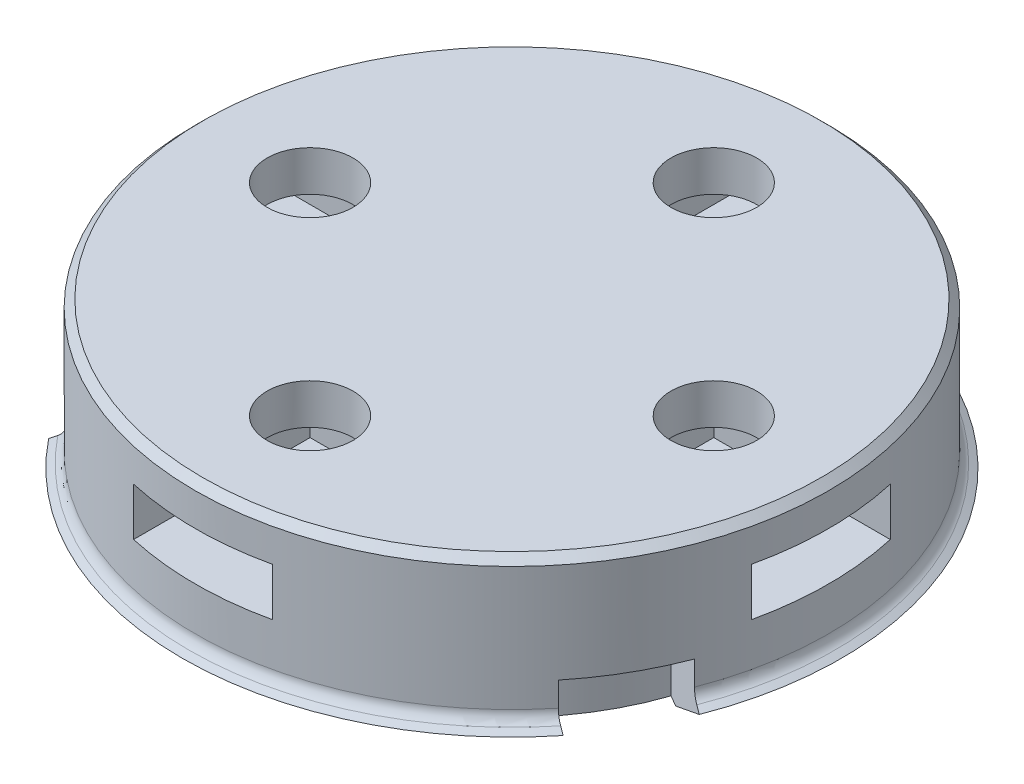
from build123d import *

# Parameters (mm, degrees)
SKETCH1_R           = 10.05
BOSS_EXTRUDE1_DEPTH = 1.746
SKETCH2_R           = 12.55
BOSS_EXTRUDE2_DEPTH = 4
SKETCH3_R           = 4.5
CUT_EXTRUDE1_DEPTH  = 6.746
SKETCH4_R           = 2.55
CUT_EXTRUDE2_DEPTH  = 2.5
SKETCH5_R           = 2
CUT_EXTRUDE3_DEPTH  = 0.3
CHAMFER1_SIZE       = 0.3
SKETCH6_R           = 1.1
CUT_EXTRUDE4_DEPTH  = 2.5
CUT_EXTRUDE5_DEPTH  = 1.7
CUT_EXTRUDE6_DEPTH  = 3
CIRPATTERN1_COUNT   = 3
FILLET1_R           = 0.5
SKETCH12_R          = 12.55
BOSS_EXTRUDE3_DEPTH = 1.5
SKETCH13_R          = 1.7
CUT_EXTRUDE7_DEPTH  = 3.5
CUT_EXTRUDE9_DEPTH  = 1.9
CHAMFER2_SIZE       = 0.3
SKETCH16_R          = 5.25
CUT_EXTRUDE10_DEPTH = 0.5
SKETCH18_R          = 1.2
BOSS_EXTRUDE4_DEPTH = 0.1


with BuildPart() as part:
    # Sketch1 → Boss-Extrude1 (new body)
    with BuildSketch(Plane(origin=(0, 0, 0), x_dir=(1, 0, 0), z_dir=(0, 1, 0))):
        Circle(SKETCH1_R)
    extrude(amount=BOSS_EXTRUDE1_DEPTH)

    # Sketch2 → Boss-Extrude2 (add)
    with BuildSketch(Plane(origin=(0, 1.746, 0), x_dir=(1, 0, 0), z_dir=(0, 1, 0))):
        Circle(SKETCH2_R)
    extrude(amount=BOSS_EXTRUDE2_DEPTH)

    # Sketch3 → Cut-Extrude1 (cut, through all)
    with BuildSketch(Plane.XZ):
        Circle(SKETCH3_R)
    extrude(amount=-CUT_EXTRUDE1_DEPTH, mode=Mode.SUBTRACT)

    # Sketch4 → Cut-Extrude2 (cut)
    with BuildSketch(Plane.XZ):
        with Locations((0, 6.75)):
            Circle(SKETCH4_R)
        with Locations((5.845671476, -3.375)):
            Circle(SKETCH4_R)
        with Locations((-5.845671476, -3.375)):
            Circle(SKETCH4_R)
    extrude(amount=-CUT_EXTRUDE2_DEPTH, mode=Mode.SUBTRACT)

    # Sketch5 → Cut-Extrude3 (cut)
    with BuildSketch(Plane.XZ.offset(-2.5)):
        with Locations((0, 6.75)):
            Circle(SKETCH5_R)
        with Locations((-5.845671476, -3.375)):
            Circle(SKETCH5_R)
        with Locations((5.845671476, -3.375)):
            Circle(SKETCH5_R)
    extrude(amount=-CUT_EXTRUDE3_DEPTH, mode=Mode.SUBTRACT)

    # Chamfer1
    chamfer1_edges = [part.edges().sort_by_distance(p)[0] for p in [
        (0, 0, 9.3),
        (8.054036255, 0, -4.65),
        (-8.054036255, 0, -4.65),
    ]]
    chamfer(chamfer1_edges, length=CHAMFER1_SIZE)

    # Sketch6 → Cut-Extrude4 (cut)
    with BuildSketch(Plane.XZ):
        with Locations((6.711696879, 3.875)):
            Circle(SKETCH6_R)
        with Locations((0, -7.75)):
            Circle(SKETCH6_R)
        with Locations((-6.711696879, 3.875)):
            Circle(SKETCH6_R)
    extrude(amount=-CUT_EXTRUDE4_DEPTH, mode=Mode.SUBTRACT)

    # Sketch10 → Revolve1 (revolve)
    with BuildSketch(Plane.XY):
        Polygon((10.05, 0), (10.05, 1.746), (12.55, 1.746), (13.062080355, 1.450350269), (10.55, 0), align=None)
    revolve(axis=Axis((0, 5.746, 0), (0, -1, 0)))

    # Sketch7 → Cut-Extrude5 (cut)
    with BuildSketch(Plane(origin=(0, 1.3, 0), x_dir=(-1, 0, 0), z_dir=(0, -1, 0))):
        Polygon((-1.975, 8.890266782), (-1.975, 18.890266782), (1.975, 18.890266782), (1.975, 8.890266782), (1.975, 6.609733218), (0, 5.469466437), (-1.975, 6.609733218), align=None)
    cut_extrude5 = extrude(amount=-CUT_EXTRUDE5_DEPTH, mode=Mode.SUBTRACT)

    # Sketch11 → Cut-Extrude6 (cut)
    with BuildSketch(Plane.XZ):
        with BuildLine():
            Line((-1.975, -19.854028364), (-1.975, -9.854028364))
            ThreePointArc((-1.975, -9.854028364), (0, -10.05), (1.975, -9.854028364))
            Line((1.975, -9.854028364), (1.975, -19.854028364))
            ThreePointArc((1.975, -19.854028364), (0, -19.952019128), (-1.975, -19.854028364))
        make_face()
    cut_extrude6 = extrude(amount=-CUT_EXTRUDE6_DEPTH, mode=Mode.SUBTRACT)

    # CirPattern1: Cut-Extrude5, Cut-Extrude6 ×3 about axis
    cirpattern1_axis = Axis((0, 0, 0), (0, 1, 0))
    for i in range(1, CIRPATTERN1_COUNT):
        add(cut_extrude5.rotate(cirpattern1_axis, i * 360 / CIRPATTERN1_COUNT), mode=Mode.SUBTRACT)
        add(cut_extrude6.rotate(cirpattern1_axis, i * 360 / CIRPATTERN1_COUNT), mode=Mode.SUBTRACT)

    # Fillet1
    fillet1_edges = [part.edges().sort_by_distance(p)[0] for p in [
        (0, 1.746, 12.55),
        (9.546956321, 1.746, -8.146049656),
        (-10.868618817, 1.746, -6.275),
    ]]
    fillet(fillet1_edges, radius=FILLET1_R)

    # Sketch12 → Boss-Extrude3 (add)
    with BuildSketch(Plane(origin=(0, 5.746, 0), x_dir=(1, 0, 0), z_dir=(0, 1, 0))):
        Circle(SKETCH12_R)
    extrude(amount=BOSS_EXTRUDE3_DEPTH)

    # Sketch13 → Cut-Extrude7 (cut)
    with BuildSketch(Plane(origin=(0, 7.246, 0), x_dir=(1, 0, 0), z_dir=(0, 1, 0))):
        with Locations((0, -8)):
            Circle(SKETCH13_R)
        with Locations((-8, 0)):
            Circle(SKETCH13_R)
        with Locations((0, 8)):
            Circle(SKETCH13_R)
        with Locations((8, 0)):
            Circle(SKETCH13_R)
    extrude(amount=-CUT_EXTRUDE7_DEPTH, mode=Mode.SUBTRACT)

    # Sketch15 → Cut-Extrude9 (cut)
    with BuildSketch(Plane(origin=(0, 3.746, 0), x_dir=(1, 0, 0), z_dir=(0, 1, 0))):
        Polygon((-2.75, -10.75), (-2.75, -15.75), (2.75, -15.75), (2.75, -10.75), (2.75, -5.25), (-2.75, -5.25), align=None)
        Polygon((-15.75, -2.75), (-10.75, -2.75), (-5.25, -2.75), (-5.25, 2.75), (-10.75, 2.75), (-15.75, 2.75), align=None)
        Polygon((-2.75, 15.75), (-2.75, 10.75), (-2.75, 5.25), (2.75, 5.25), (2.75, 10.75), (2.75, 15.75), align=None)
        Polygon((15.75, 2.75), (10.75, 2.75), (5.25, 2.75), (5.25, -2.75), (10.75, -2.75), (15.75, -2.75), align=None)
    extrude(amount=CUT_EXTRUDE9_DEPTH, mode=Mode.SUBTRACT)

    # Chamfer2
    chamfer2_edges = [part.edges().sort_by_distance(p)[0] for p in [
        (-12.55, 7.246, 0),
    ]]
    chamfer(chamfer2_edges, length=CHAMFER2_SIZE)

    # Sketch16 → Cut-Extrude10 (cut)
    with BuildSketch(Plane.XZ):
        with Locations((0, 6.75)):
            Circle(SKETCH16_R)
        with Locations((-5.845671476, -3.375)):
            Circle(SKETCH16_R)
        with Locations((5.845671476, -3.375)):
            Circle(SKETCH16_R)
    extrude(amount=-CUT_EXTRUDE10_DEPTH, mode=Mode.SUBTRACT)

    # Sketch18 → Boss-Extrude4 (add)
    with BuildSketch(Plane(origin=(0, 1.3, 0), x_dir=(1, 0, 0), z_dir=(0, 1, 0))):
        with Locations((6.711696879, -3.875)):
            Circle(SKETCH18_R)
        with Locations((0, 7.75)):
            Circle(SKETCH18_R)
        with Locations((-6.711696879, -3.875)):
            Circle(SKETCH18_R)
    extrude(amount=-BOSS_EXTRUDE4_DEPTH)


solid = part.part
